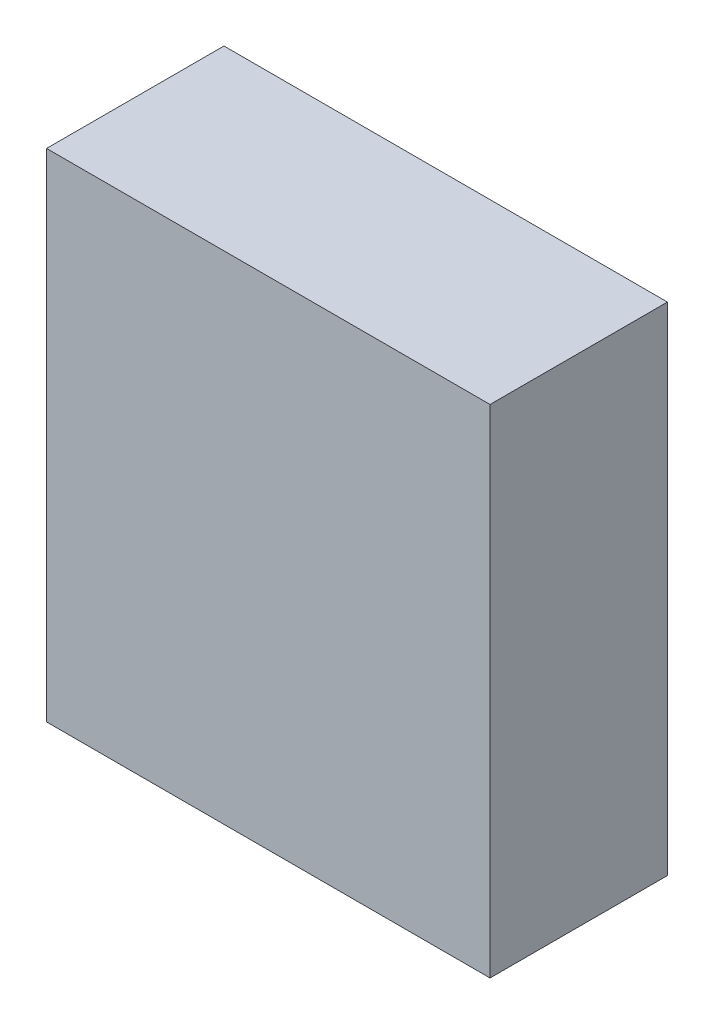
from build123d import *

# Parameters (mm, degrees)
SKETCH1_W           = 250
SKETCH1_H           = 280
BOSS_EXTRUDE1_DEPTH = 100


with BuildPart() as part:
    # Sketch1 → Boss-Extrude1 (new body)
    with BuildSketch(Plane.XY):
        Rectangle(SKETCH1_W, SKETCH1_H)
    extrude(amount=BOSS_EXTRUDE1_DEPTH)


solid = part.part
